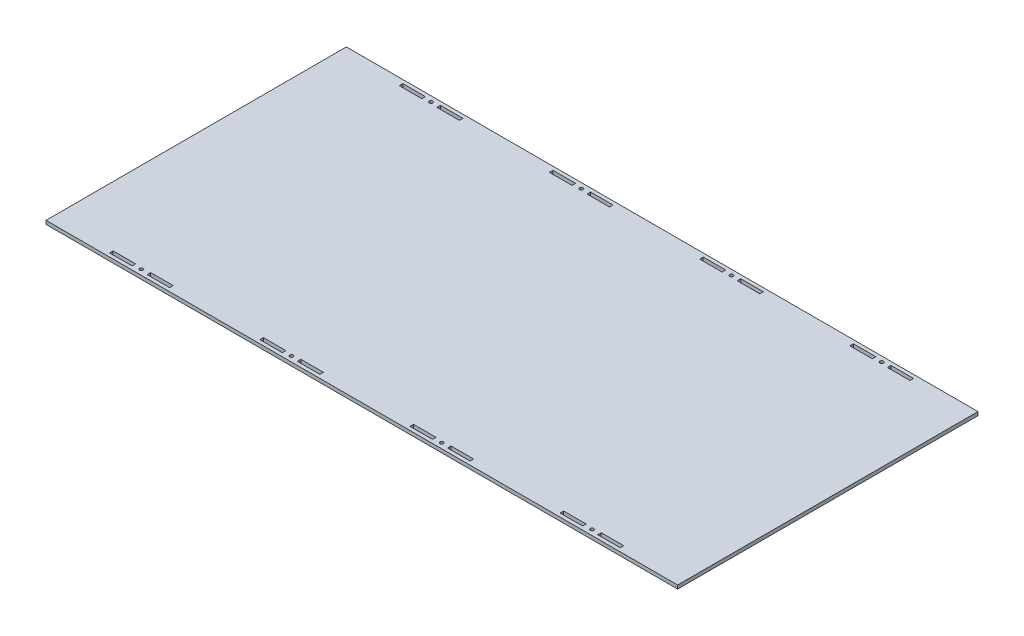
from build123d import *

# Parameters (mm, degrees)
SKETCH1_W             = 534.162
SKETCH1_H             = 254
BOSS_EXTRUDE1_DEPTH   = 3
SKETCH2_W             = 19.05
SKETCH2_H             = 3
CUT_EXTRUDE1_DEPTH    = 4
F_4_CLEARANCE_HOLE1_D = 2.9464


with BuildPart() as part:
    # Sketch1 → Boss-Extrude1 (new body)
    with BuildSketch(Plane(origin=(0, 0, 0), x_dir=(1, 0, 0), z_dir=(0, 1, 0))):
        with Locations((267.081, 127)):
            Rectangle(SKETCH1_W, SKETCH1_H)
    extrude(amount=BOSS_EXTRUDE1_DEPTH)

    # Sketch2 → Cut-Extrude1 (cut, through all)
    with BuildSketch(Plane(origin=(0, 3, 0), x_dir=(1, 0, 0), z_dir=(0, 1, 0))):
        with Locations((60.325, 4.5)):
            Rectangle(SKETCH2_W, SKETCH2_H)
        with Locations((92.075, 4.5)):
            Rectangle(SKETCH2_W, SKETCH2_H)
        with Locations((187.325, 4.5)):
            Rectangle(SKETCH2_W, SKETCH2_H)
        with Locations((219.075, 4.5)):
            Rectangle(SKETCH2_W, SKETCH2_H)
        with Locations((314.325, 4.5)):
            Rectangle(SKETCH2_W, SKETCH2_H)
        with Locations((346.075, 4.5)):
            Rectangle(SKETCH2_W, SKETCH2_H)
        with Locations((441.325, 4.5)):
            Rectangle(SKETCH2_W, SKETCH2_H)
        with Locations((473.075, 4.5)):
            Rectangle(SKETCH2_W, SKETCH2_H)
        with Locations((60.325, 249.5)):
            Rectangle(SKETCH2_W, SKETCH2_H)
        with Locations((92.075, 249.5)):
            Rectangle(SKETCH2_W, SKETCH2_H)
        with Locations((187.325, 249.5)):
            Rectangle(SKETCH2_W, SKETCH2_H)
        with Locations((219.075, 249.5)):
            Rectangle(SKETCH2_W, SKETCH2_H)
        with Locations((314.325, 249.5)):
            Rectangle(SKETCH2_W, SKETCH2_H)
        with Locations((346.075, 249.5)):
            Rectangle(SKETCH2_W, SKETCH2_H)
        with Locations((441.325, 249.5)):
            Rectangle(SKETCH2_W, SKETCH2_H)
        with Locations((473.075, 249.5)):
            Rectangle(SKETCH2_W, SKETCH2_H)
    extrude(amount=-CUT_EXTRUDE1_DEPTH, mode=Mode.SUBTRACT)

    # #4 Clearance Hole1 (through all)
    with Locations(Plane(origin=(0, 3, 0), x_dir=(1, 0, 0), z_dir=(0, 1, 0))):
        with Locations((76.2, 249.5), (203.2, 249.5), (330.2, 249.5), (457.2, 249.5), (457.2, 4.5), (330.2, 4.5), (203.2, 4.5), (76.2, 4.5)):
            Hole(F_4_CLEARANCE_HOLE1_D / 2)


solid = part.part
